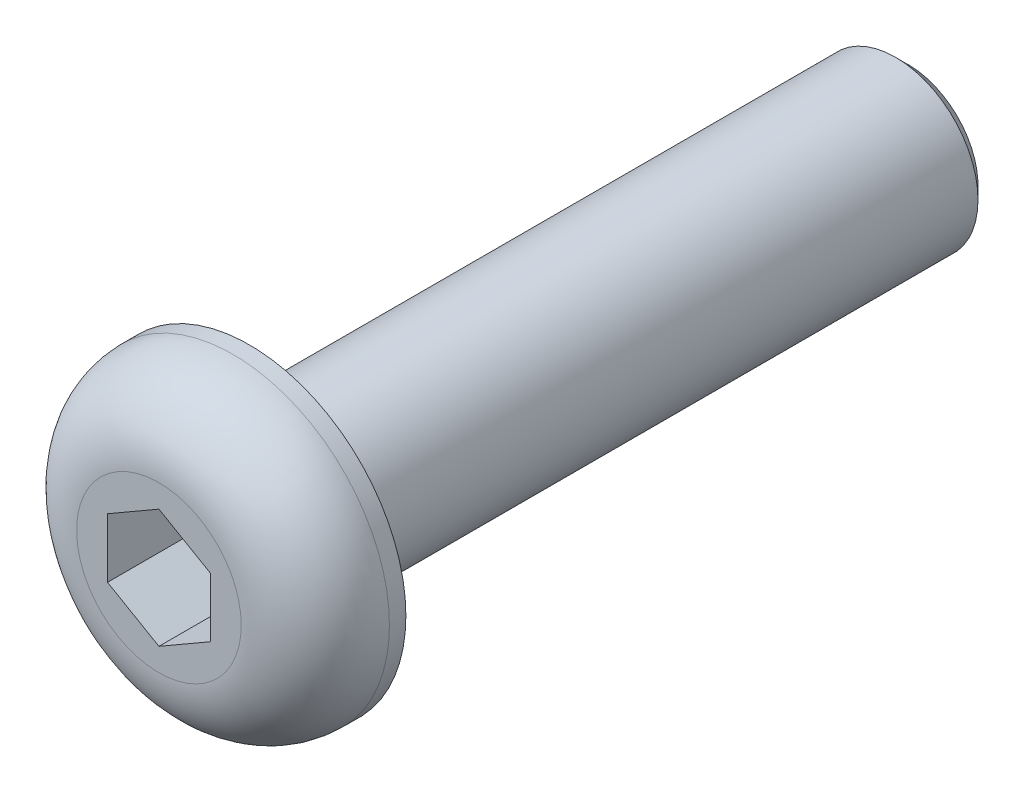
from build123d import *

# Parameters (mm, degrees)
SKETCH1_R           = 3.8
BOSS_EXTRUDE1_DEPTH = 2.2
SKETCH2_R           = 2
BOSS_EXTRUDE2_DEPTH = 16
CHAMFER1_SIZE       = 0.3
CUT_EXTRUDE1_DEPTH  = 2
FILLET1_R           = 1.8


with BuildPart() as part:
    # Sketch1 → Boss-Extrude1 (new body)
    with BuildSketch(Plane.XY):
        Circle(SKETCH1_R)
    extrude(amount=BOSS_EXTRUDE1_DEPTH)

    # Sketch2 → Boss-Extrude2 (add)
    with BuildSketch(Plane(origin=(0, 0, 0), x_dir=(-1, 0, 0), z_dir=(0, 0, -1))):
        Circle(SKETCH2_R)
    extrude(amount=BOSS_EXTRUDE2_DEPTH)

    # Chamfer1
    chamfer1_edges = [part.edges().sort_by_distance(p)[0] for p in [
        (2, 0, -16),
    ]]
    chamfer(chamfer1_edges, length=CHAMFER1_SIZE)

    # Sketch3 → Cut-Extrude1 (cut)
    with BuildSketch(Plane.XY.offset(2.2)):
        Polygon((0, 1.443375673), (-1.25, 0.721687836), (-1.25, -0.721687836), (0, -1.443375673), (1.25, -0.721687836), (1.25, 0.721687836), align=None)
    extrude(amount=-CUT_EXTRUDE1_DEPTH, mode=Mode.SUBTRACT)

    # Fillet1
    fillet1_edges = [part.edges().sort_by_distance(p)[0] for p in [
        (-3.8, 0, 2.2),
    ]]
    fillet(fillet1_edges, radius=FILLET1_R)


solid = part.part
